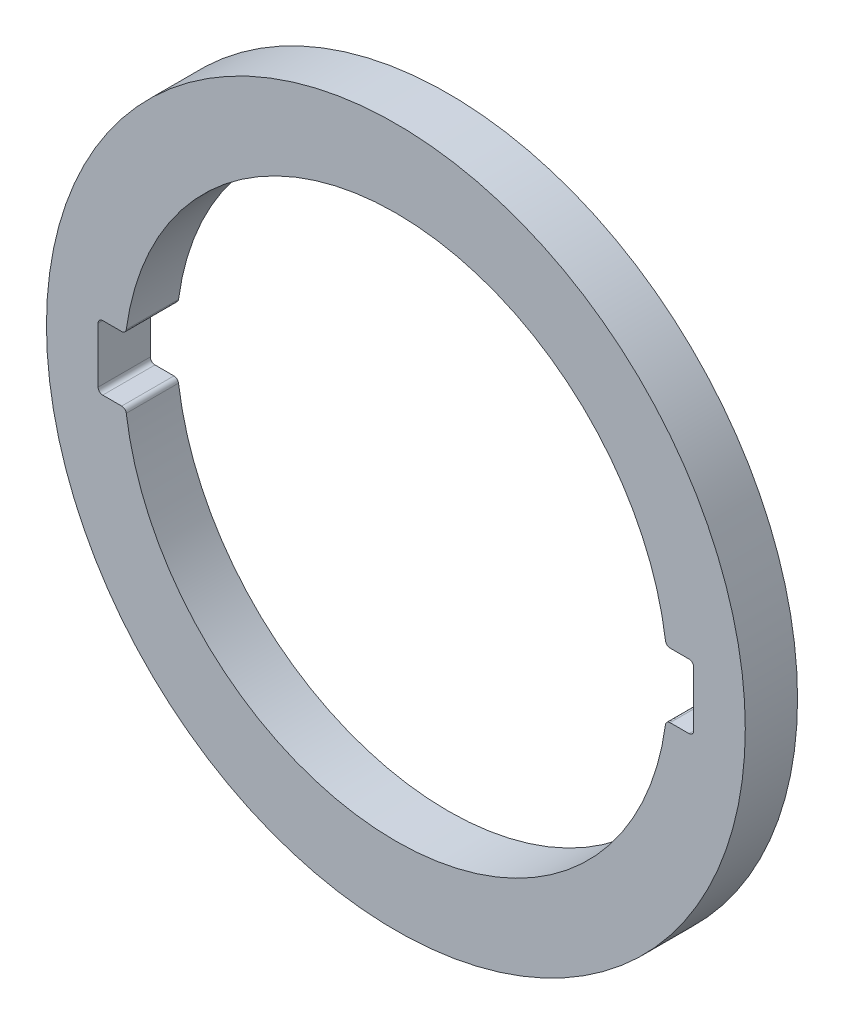
from build123d import *

# Parameters (mm, degrees)
IZIM1_R                          = 1136.77987901
Y_KSEKLIK_EKSTR_ZYON1_DEPTH      = 30
Y_KSEKLIK_EKSTR_ZYON1_DEPTH_BACK = 140
RADYUS1_R                        = 15


with BuildPart() as part:
    # Çizim1 → Yükseklik-Ekstrüzyon1 (new body, two sides)
    with BuildSketch(Plane.XY) as y_kseklik_ekstr_zyon1_sk:
        with Locations((-290.901455233, 947.5)):
            Circle(IZIM1_R)
        with BuildLine():
            Line((587.84765572, 842.5), (662.84765572, 842.5))
            ThreePointArc((662.84765572, 842.5), (673.454257437, 846.893398282), (677.84765572, 857.5))
            Line((677.84765572, 857.5), (677.84765572, 1037.5))
            ThreePointArc((677.84765572, 1037.5), (673.454257437, 1048.106601718), (662.84765572, 1052.5))
            Line((662.84765572, 1052.5), (587.84765572, 1052.5))
            ThreePointArc((587.84765572, 1052.5), (-290.901455233, 1832.5), (-1169.650566186, 1052.5))
            Line((-1169.650566186, 1052.5), (-1244.650566186, 1052.5))
            ThreePointArc((-1244.650566186, 1052.5), (-1255.257167903, 1048.106601718), (-1259.650566186, 1037.5))
            Line((-1259.650566186, 1037.5), (-1259.650566186, 857.5))
            ThreePointArc((-1259.650566186, 857.5), (-1255.257167903, 846.893398282), (-1244.650566186, 842.5))
            Line((-1244.650566186, 842.5), (-1169.650566186, 842.5))
            ThreePointArc((-1169.650566186, 842.5), (-290.901455233, 62.5), (587.84765572, 842.5))
        make_face(mode=Mode.SUBTRACT)
    extrude(amount=Y_KSEKLIK_EKSTR_ZYON1_DEPTH)
    extrude(y_kseklik_ekstr_zyon1_sk.sketch, amount=-Y_KSEKLIK_EKSTR_ZYON1_DEPTH_BACK)

    # Radyus1
    radyus1_edges = [part.edges().sort_by_distance(p)[0] for p in [
        (587.84765572, 842.5, -70),
        (-1169.650566186, 842.5, -70),
        (-1169.650566186, 1052.5, -70),
        (587.84765572, 1052.5, -70),
    ]]
    fillet(radyus1_edges, radius=RADYUS1_R)


solid = part.part
